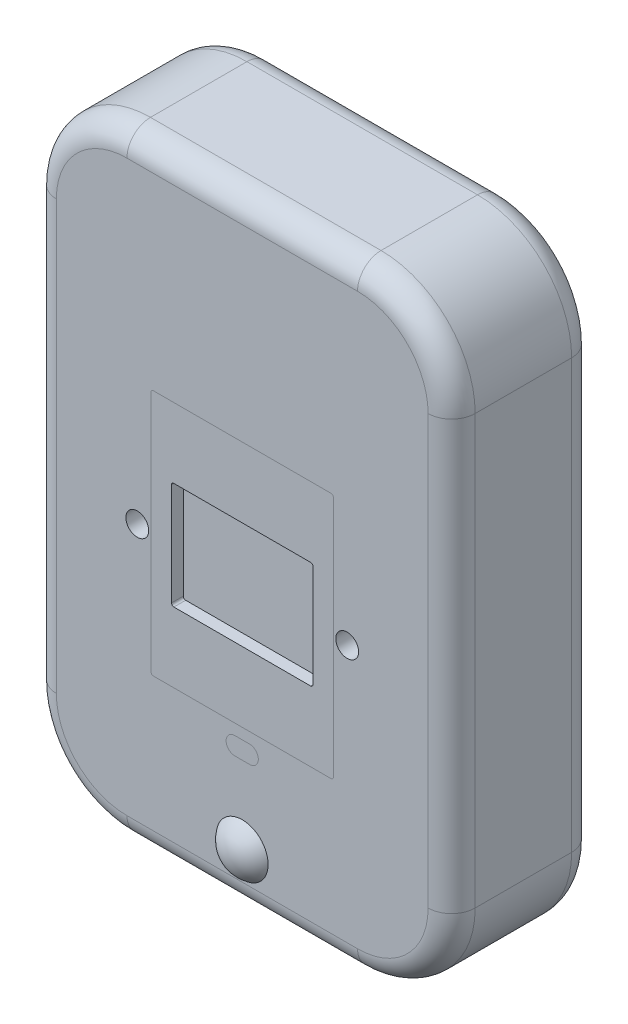
from build123d import *

# Parameters (mm, degrees)
BOSS_EXTRUDE1_DEPTH            = 30.5
CUT_EXTRUDE1_START             = 30.5
CUT_EXTRUDE1_DEPTH             = 5
CBORE_FOR_M4_SHCS1_D           = 4.5
CBORE_FOR_M4_SHCS1_CBORE_D     = 9.7
CBORE_FOR_M4_SHCS1_CBORE_DEPTH = 55.5
F_1_4_20_TAPPED_HOLE1_D        = 5.1054
F_1_4_20_TAPPED_HOLE1_DEPTH    = 12
FILLET1_R                      = 10
SKETCH8_W                      = 15.1
SKETCH8_H                      = 20.9
BOSS_EXTRUDE2_DEPTH            = 5


with BuildPart() as part:
    # Sketch1 → Boss-Extrude1 (new body, symmetric)
    with BuildSketch(Plane.XY):
        with BuildLine():
            Line((-49, 131), (49, 131))
            ThreePointArc((49, 131), (77.284271247, 119.284271247), (89, 91))
            Line((89, 91), (89, -91))
            ThreePointArc((89, -91), (77.284271247, -119.284271247), (49, -131))
            Line((49, -131), (-49, -131))
            ThreePointArc((-49, -131), (-77.284271247, -119.284271247), (-89, -91))
            Line((-89, -91), (-89, 91))
            ThreePointArc((-89, 91), (-77.284271247, 119.284271247), (-49, 131))
        make_face()
    extrude(amount=BOSS_EXTRUDE1_DEPTH, both=True)

    # Sketch1_4 → Cut-Extrude1 (cut)
    with BuildSketch(Plane.XY.offset(CUT_EXTRUDE1_START)):
        with BuildLine():
            Line((-29.05, 11.25), (29.05, 11.25))
            ThreePointArc((29.05, 11.25), (29.757106781, 10.957106781), (30.05, 10.25))
            Line((30.05, 10.25), (30.05, -33.25))
            ThreePointArc((30.05, -33.25), (29.757106781, -33.957106781), (29.05, -34.25))
            Line((29.05, -34.25), (-29.05, -34.25))
            ThreePointArc((-29.05, -34.25), (-29.757106781, -33.957106781), (-30.05, -33.25))
            Line((-30.05, -33.25), (-30.05, 10.25))
            ThreePointArc((-30.05, 10.25), (-29.757106781, 10.957106781), (-29.05, 11.25))
        make_face()
    extrude(amount=-CUT_EXTRUDE1_DEPTH, mode=Mode.SUBTRACT)

    # CBORE for M4 SHCS1 (through all)
    with Locations(Plane.XY.offset(30.5)):
        with Locations((-44.6, -11.5), (44.6, -11.5)):
            CounterBoreHole(CBORE_FOR_M4_SHCS1_D / 2, CBORE_FOR_M4_SHCS1_CBORE_D / 2, CBORE_FOR_M4_SHCS1_CBORE_DEPTH)

    # 1_4-20 Tapped Hole1
    with Locations(Plane(origin=(0, 0, -30.5), x_dir=(-1, 0, 0), z_dir=(0, 0, -1))):
        with Locations((0, 12)):
            Hole(F_1_4_20_TAPPED_HOLE1_D / 2, depth=F_1_4_20_TAPPED_HOLE1_DEPTH)

    # Sketch4 → Revolve1 (revolve)
    with BuildSketch(Plane(origin=(0, 0, 0), x_dir=(0, 0, -1), z_dir=(1, 0, 0))):
        with BuildLine():
            Line((-36.4, -109), (-9.991525424, -109))
            ThreePointArc((-9.991525424, -109), (-23.195762712, -95.795762712), (-36.4, -109))
        make_face()
    revolve(axis=Axis((0, -109, 157.281610428), (0, 0, -1)))

    # Fillet1
    fillet1_edges = [part.edges().sort_by_distance(p)[0] for p in [
        (77.284271247, 119.284271247, -30.5),
        (0, 131, 30.5),
        (89, 0, -30.5),
        (77.284271247, -119.284271247, -30.5),
        (0, -131, -30.5),
        (-77.284271247, -119.284271247, -30.5),
        (-89, 0, -30.5),
        (-77.284271247, 119.284271247, -30.5),
        (0, 131, -30.5),
        (-77.284271247, 119.284271247, 30.5),
        (-89, 0, 30.5),
        (-77.284271247, -119.284271247, 30.5),
        (0, -131, 30.5),
        (77.284271247, -119.284271247, 30.5),
        (89, 0, 30.5),
        (77.284271247, 119.284271247, 30.5),
    ]]
    fillet(fillet1_edges, radius=FILLET1_R)

    # Sketch8 → Boss-Extrude2 (add)
    with BuildSketch(Plane.ZY.offset(89)):
        with Locations((0, 70.55)):
            Rectangle(SKETCH8_W, SKETCH8_H)
    extrude(amount=BOSS_EXTRUDE2_DEPTH)


solid = part.part
